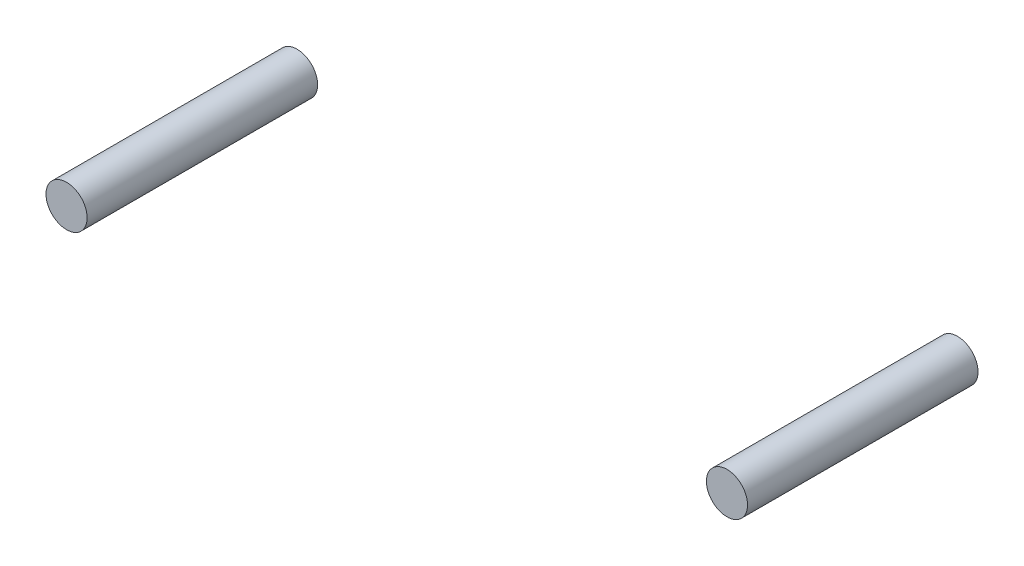
from build123d import *

# Parameters (mm, degrees)
SKETCH2_R             = 6.35
BOSS_EXTRUDE1_DEPTH   = 71.1581
BOSS_EXTRUDE1_2_DEPTH = 71.1581


with BuildPart() as part:
    # Sketch2 → Boss-Extrude1 (new body)
    with BuildSketch(Plane(origin=(0, 0, -22.86), x_dir=(-1, 0, 0), z_dir=(0, 0, -1))):
        with Locations((203.888829504, -25.174417137)):
            Circle(SKETCH2_R)
    extrude(amount=-BOSS_EXTRUDE1_DEPTH)


with BuildPart() as body_2:
    # Sketch2 → Boss-Extrude1 2 (new body)
    with BuildSketch(Plane(origin=(0, 0, -22.86), x_dir=(-1, 0, 0), z_dir=(0, 0, -1))):
        Circle(SKETCH2_R)
    extrude(amount=-BOSS_EXTRUDE1_2_DEPTH)


solid = Compound([part.part, body_2.part])
